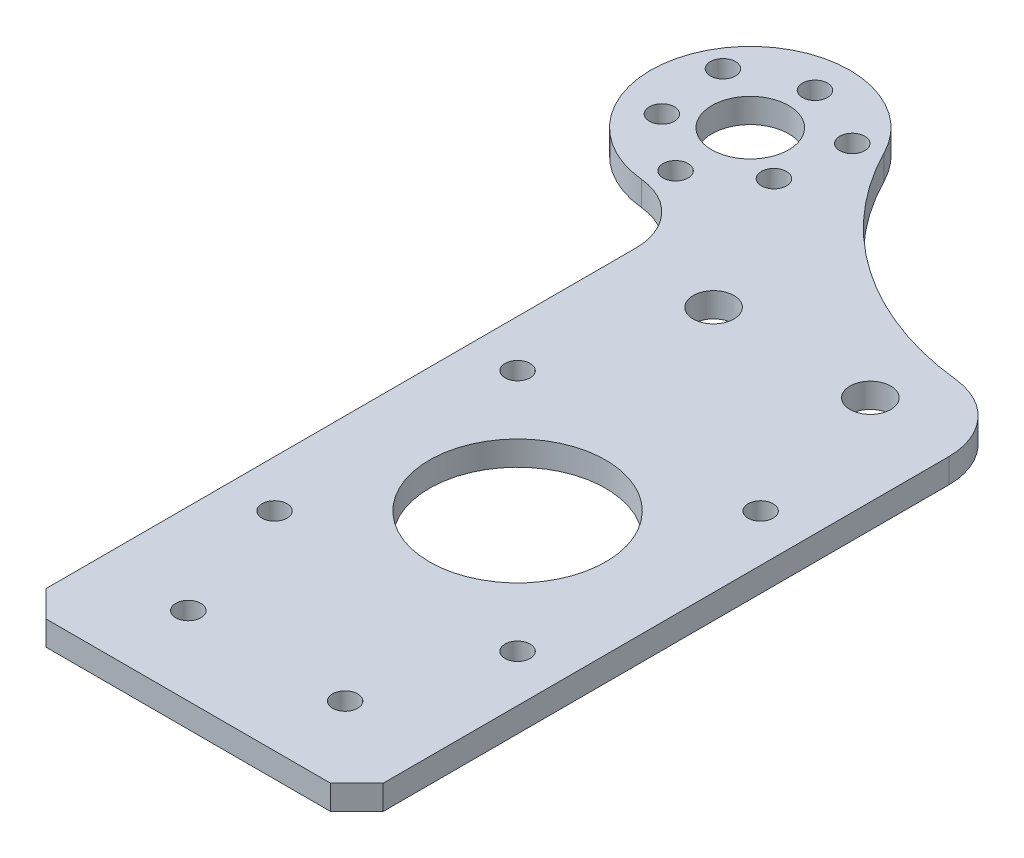
from build123d import *

# Parameters (mm, degrees)
SKETCH1_R           = 4.9
SKETCH1_R_2         = 2.6
SKETCH1_R_3         = 1.6
SKETCH1_R_4         = 11.25
BOSS_EXTRUDE1_DEPTH = 3.125
FILLET1_R           = 8
CUT_EXTRUDE1_REACH  = 5.125
SKETCH3_R           = 1.6


with BuildPart() as part:
    # Sketch1 → Boss-Extrude1 (new body)
    with BuildSketch(Plane(origin=(0, 0, 0), x_dir=(1, 0, 0), z_dir=(0, 1, 0))):
        with BuildLine():
            Line((-27.5, 86.48), (-21.5, 86.48))
            Line((-21.5, 86.48), (-21.5, 3.35))
            Line((-21.5, 3.35), (-18.15, 0))
            Line((-18.15, 0), (18.15, 0))
            Line((18.15, 0), (21.5, 3.35))
            Line((21.5, 3.35), (21.5, 75.517491819))
            ThreePointArc((21.5, 75.517491819), (19.195241391, 81.531952951), (13.461390508, 84.465996068))
            ThreePointArc((13.461390508, 84.465996068), (-3.952756456, 90.933879006), (-16.17349063, 104.924578791))
            ThreePointArc((-16.17349063, 104.924578791), (-38.32234149, 105.825820091), (-27.5, 86.48))
        make_face()
        with Locations((-27.5, 99.18)):
            Circle(SKETCH1_R, mode=Mode.SUBTRACT)
        with Locations((10, 77)):
            Circle(SKETCH1_R_2, mode=Mode.SUBTRACT)
        with Locations((-10, 77)):
            Circle(SKETCH1_R_2, mode=Mode.SUBTRACT)
        with Locations((10, 10)):
            Circle(SKETCH1_R_3, mode=Mode.SUBTRACT)
        with Locations((-10, 10)):
            Circle(SKETCH1_R_3, mode=Mode.SUBTRACT)
        with Locations((-20.355290419, 95.055)):
            Circle(SKETCH1_R_3, mode=Mode.SUBTRACT)
        with Locations((-34.644709581, 95.055)):
            Circle(SKETCH1_R_3, mode=Mode.SUBTRACT)
        with Locations((-27.5, 107.43)):
            Circle(SKETCH1_R_3, mode=Mode.SUBTRACT)
        with Locations((0, 42)):
            Circle(SKETCH1_R_4, mode=Mode.SUBTRACT)
        with Locations((-15.5, 26.5)):
            Circle(SKETCH1_R_3, mode=Mode.SUBTRACT)
        with Locations((-15.5, 57.5)):
            Circle(SKETCH1_R_3, mode=Mode.SUBTRACT)
        with Locations((15.5, 57.5)):
            Circle(SKETCH1_R_3, mode=Mode.SUBTRACT)
        with Locations((15.5, 26.5)):
            Circle(SKETCH1_R_3, mode=Mode.SUBTRACT)
    extrude(amount=BOSS_EXTRUDE1_DEPTH)

    # Fillet1
    fillet1_edges = [part.edges().sort_by_distance(p)[0] for p in [
        (-21.5, 1.5625, -86.48),
    ]]
    fillet(fillet1_edges, radius=FILLET1_R)

    # Sketch3 → Cut-Extrude1 (cut, up to next)
    with BuildSketch(Plane(origin=(0, 3.125, 0), x_dir=(1, 0, 0), z_dir=(0, 1, 0)), mode=Mode.PRIVATE) as cut_extrude1_sk1:
        with Locations((-27.5, 89.653720558)):
            Circle(SKETCH3_R)
    cut_extrude1_tool1 = extrude(cut_extrude1_sk1.sketch, amount=-CUT_EXTRUDE1_REACH, mode=Mode.PRIVATE) & part.part
    add(cut_extrude1_tool1.solids().sort_by_distance((-27.5, 3.125, -89.653721))[0], mode=Mode.SUBTRACT)
    # Sketch3 → Cut-Extrude1 (cut, up to next)
    with BuildSketch(Plane(origin=(0, 3.125, 0), x_dir=(1, 0, 0), z_dir=(0, 1, 0)), mode=Mode.PRIVATE) as cut_extrude1_sk2:
        with Locations((-35.75, 103.943139721)):
            Circle(SKETCH3_R)
    cut_extrude1_tool2 = extrude(cut_extrude1_sk2.sketch, amount=-CUT_EXTRUDE1_REACH, mode=Mode.PRIVATE) & part.part
    add(cut_extrude1_tool2.solids().sort_by_distance((-35.75, 3.125, -103.94314))[0], mode=Mode.SUBTRACT)
    # Sketch3 → Cut-Extrude1 (cut, up to next)
    with BuildSketch(Plane(origin=(0, 3.125, 0), x_dir=(1, 0, 0), z_dir=(0, 1, 0)), mode=Mode.PRIVATE) as cut_extrude1_sk3:
        with Locations((-19.25, 103.943139721)):
            Circle(SKETCH3_R)
    cut_extrude1_tool3 = extrude(cut_extrude1_sk3.sketch, amount=-CUT_EXTRUDE1_REACH, mode=Mode.PRIVATE) & part.part
    add(cut_extrude1_tool3.solids().sort_by_distance((-19.25, 3.125, -103.94314))[0], mode=Mode.SUBTRACT)


solid = part.part
